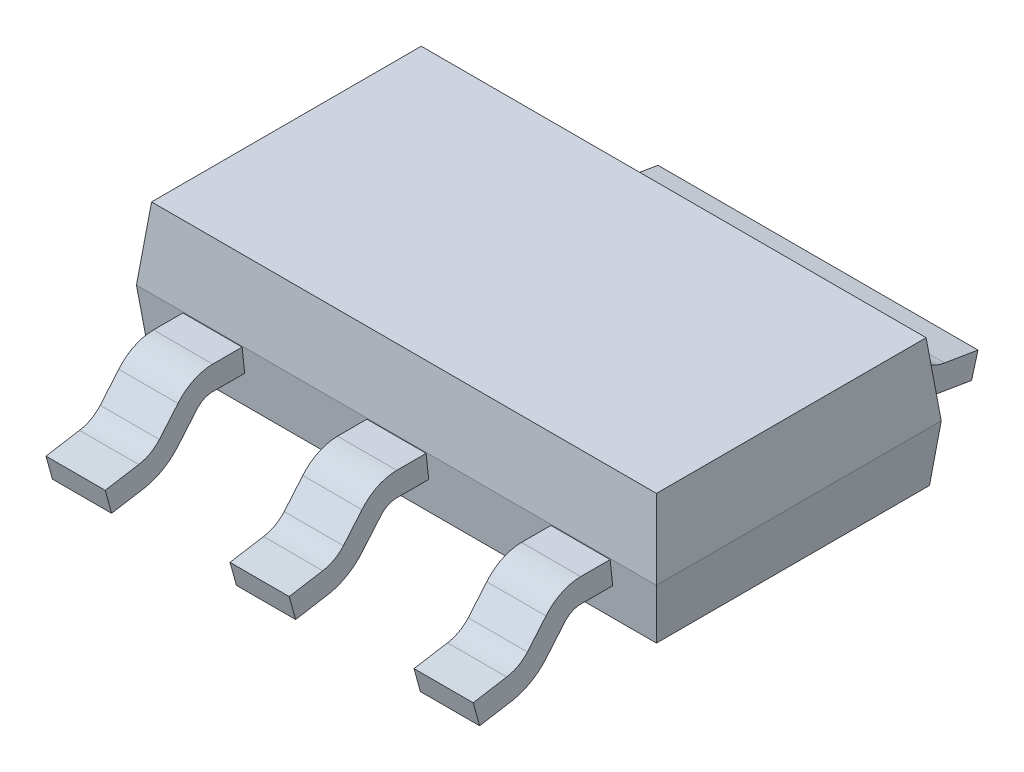
from build123d import *

# Parameters (mm, degrees)
ESBO_O1_W                 = 6.5
ESBO_O1_H                 = 3.56
EXTRUS_O1_DEPTH           = 0.9
EXTRUS_O1_TAPER           = 6
EXTRUS_O1_OTHER_WAY_DEPTH = 0.7
EXTRUS_O1_OTHER_WAY_TAPER = 6
ESBO_O3_W                 = 0.74
ESBO_O3_H                 = 0.3
PADR_O_LINEAR1_COUNT      = 2
PADR_O_LINEAR1_PITCH      = 2.3
PADR_O_LINEAR1_COL_COUNT  = 2
PADR_O_LINEAR1_COL_PITCH  = 2.3
ESBO_O5_W                 = 4
ESBO_O5_H                 = 0.3


with BuildPart() as part:
    # Esboço1 → Extrusão1 (new body)
    with BuildSketch(Plane(origin=(0, 0, 0), x_dir=(1, 0, 0), z_dir=(0, 1, 0))):
        Rectangle(ESBO_O1_W, ESBO_O1_H)
    extrude(amount=EXTRUS_O1_DEPTH, taper=EXTRUS_O1_TAPER)

    # Esboço1 → Extrusão1 other way (add)
    with BuildSketch(Plane(origin=(0, 0, 0), x_dir=(1, 0, 0), z_dir=(0, 1, 0))):
        Rectangle(ESBO_O1_W, ESBO_O1_H)
    extrude(amount=-EXTRUS_O1_OTHER_WAY_DEPTH, taper=EXTRUS_O1_OTHER_WAY_TAPER)

    # Varredura1: sweep along a path in Esboço2
    with BuildLine(Plane(origin=(0, 0, 0), x_dir=(0, 0, -1), z_dir=(1, 0, 0))) as varredura1_path:
        Line((-1.771086264, -0.084808537), (-2.138904869, -0.084808537))
        ThreePointArc((-2.138904869, -0.084808537), (-2.349489276, -0.131317404), (-2.520897515, -0.262191707))
        Line((-2.520897515, -0.262191707), (-2.752531862, -0.536457055))
        ThreePointArc((-2.752531862, -0.536457055), (-2.88725344, -0.648417053), (-3.052325014, -0.707037188))
        Line((-3.052325014, -0.707037188), (-3.471086264, -0.776830729))
    # Esboço3 → Varredura1 (sweep)
    with BuildSketch(Plane(origin=(0, -0.185041405, 1.760551365), x_dir=(1, 0, 0), z_dir=(0, -0.104528463, 0.994521895))):
        with Locations((0, 0.023347308)):
            Rectangle(ESBO_O3_W, ESBO_O3_H)
    varredura1 = sweep(path=varredura1_path.line)

    # Padrão linear1: Varredura1 ×2
    with Locations(*[(i * PADR_O_LINEAR1_PITCH, 0, 0) for i in range(1, PADR_O_LINEAR1_COUNT)]):
        add(varredura1)

    # Padrão linear1 col: Varredura1 ×2
    with Locations(*[(-i * PADR_O_LINEAR1_COL_PITCH, 0, 0) for i in range(1, PADR_O_LINEAR1_COL_COUNT)]):
        add(varredura1)

    # Varredura2: sweep along a path in Esboço4
    with BuildLine(Plane(origin=(0, 0, 0), x_dir=(0, 0, -1), z_dir=(1, 0, 0))) as varredura2_path:
        Line((1.770334988, -0.091956448), (2.13866613, -0.091956448))
        ThreePointArc((2.13866613, -0.091956448), (2.34886791, -0.138287834), (2.52011393, -0.2686956))
        Line((2.52011393, -0.2686956), (2.751853347, -0.542148112))
        ThreePointArc((2.751853347, -0.542148112), (2.886396765, -0.653672528), (3.051101653, -0.712084226))
        Line((3.051101653, -0.712084226), (3.470334988, -0.781956448))
    # Esboço5 → Varredura2 (sweep)
    with BuildSketch(Plane(origin=(0, -0.185041405, -1.760551365), x_dir=(-1, 0, 0), z_dir=(0, -0.104528463, -0.994521895))):
        with Locations((0, 0.014790466)):
            Rectangle(ESBO_O5_W, ESBO_O5_H)
    sweep(path=varredura2_path.line)


solid = part.part
